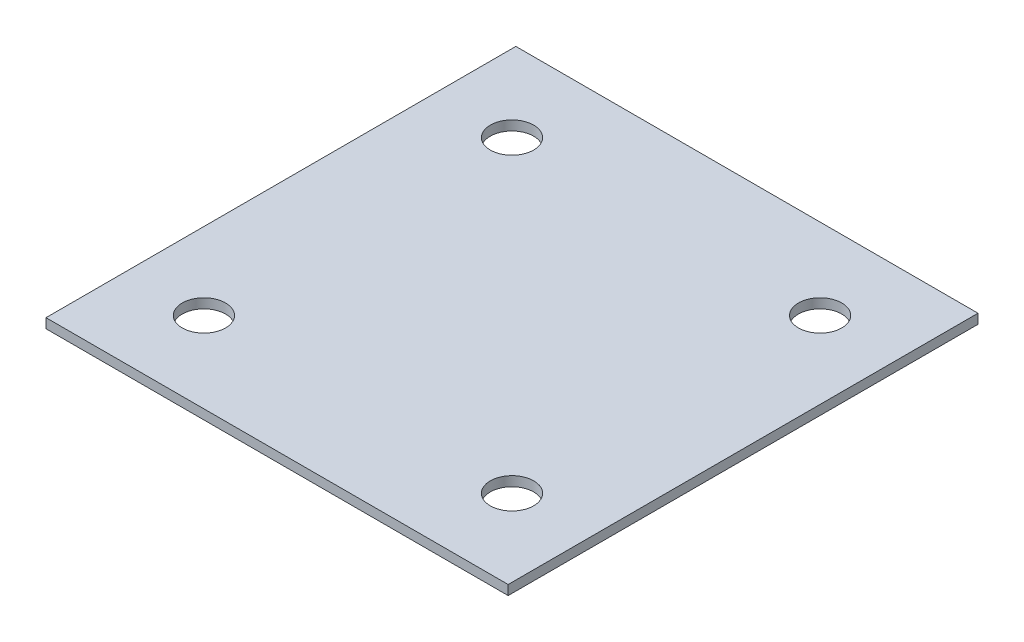
from build123d import *

# Parameters (mm, degrees)
SKETCH1_W           = 304.8
SKETCH1_H           = 309.88
SKETCH1_R           = 14.2875
BOSS_EXTRUDE1_DEPTH = 3.175


with BuildPart() as part:
    # Sketch1 → Boss-Extrude1 (new body, symmetric)
    with BuildSketch(Plane(origin=(0, 0, 0), x_dir=(1, 0, 0), z_dir=(0, 1, 0))):
        with Locations((152.4, 154.94)):
            Rectangle(SKETCH1_W, SKETCH1_H)
        with Locations((50.8, 53.34)):
            Circle(SKETCH1_R, mode=Mode.SUBTRACT)
        with Locations((254, 53.34)):
            Circle(SKETCH1_R, mode=Mode.SUBTRACT)
        with Locations((50.8, 256.54)):
            Circle(SKETCH1_R, mode=Mode.SUBTRACT)
        with Locations((254, 256.54)):
            Circle(SKETCH1_R, mode=Mode.SUBTRACT)
    extrude(amount=BOSS_EXTRUDE1_DEPTH, both=True)


solid = part.part
